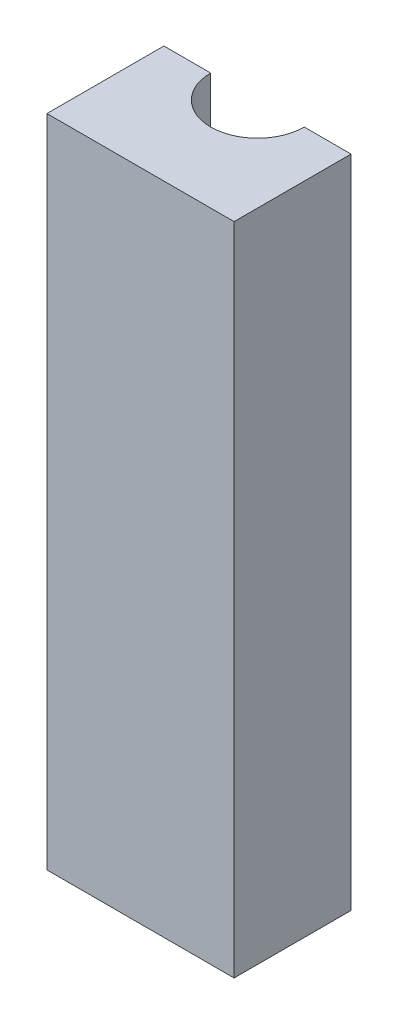
from build123d import *

# Parameters (mm, degrees)
BOSS_EXTRUDE1_DEPTH = 140


with BuildPart() as part:
    # Sketch4 → Boss-Extrude1 (new body)
    with BuildSketch(Plane(origin=(0, 0, 0), x_dir=(1, 0, 0), z_dir=(0, 1, 0))):
        with BuildLine():
            ThreePointArc((10, 0), (0, -10), (-10, 0))
            Line((-10, 0), (-20, 0))
            Line((-20, 0), (-20, -25))
            Line((-20, -25), (20, -25))
            Line((20, -25), (20, 0))
            Line((20, 0), (10, 0))
        make_face()
    extrude(amount=-BOSS_EXTRUDE1_DEPTH)


solid = part.part
